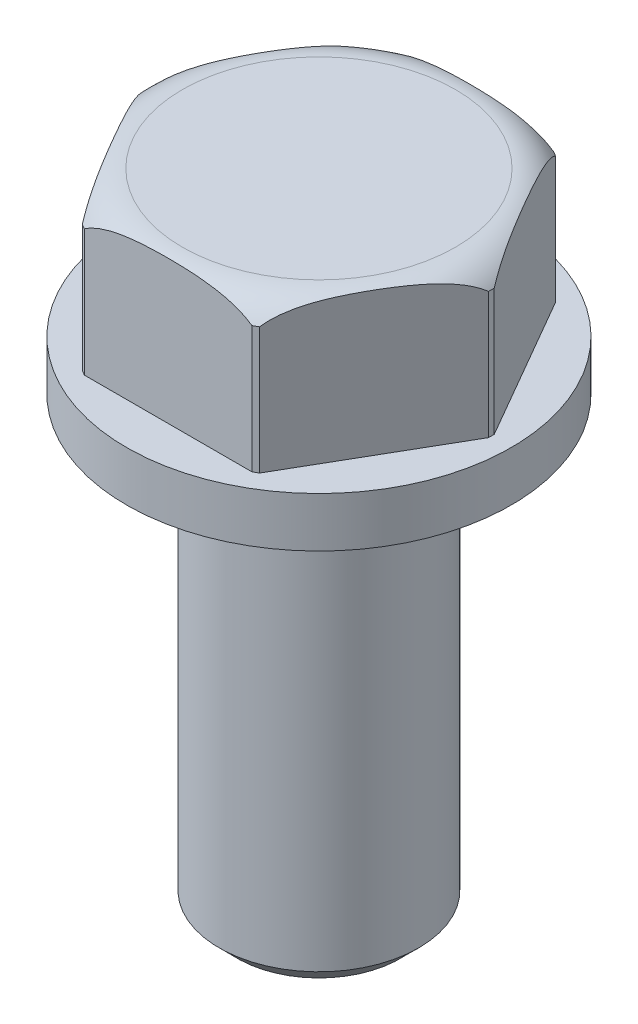
from build123d import *

# Parameters (mm, degrees)
SKETCH2_W          = 10.668
SKETCH2_H          = 4.111930553
CUT_EXTRUDE1_DEPTH = 9.271
CIRPATTERN1_COUNT  = 6
CHAMFER1_SIZE      = 1.16332


with BuildPart() as part:
    # Sketch1 → Revolve1 (revolve)
    with BuildSketch(Plane.XY):
        Polygon((0, 0), (6.35, 0), (6.35, 28.5496), (12.2555, 28.5496), (12.2555, 31.7246), (10.9855, 31.7246), (10.9855, 40.9956), (0, 40.9956), align=None)
    revolve(axis=Axis((0, 40.9956, 0), (0, -1, 0)))

    # Sketch2 → Cut-Extrude1 (cut)
    with BuildSketch(Plane(origin=(0, 40.9956, 0), x_dir=(1, 0, 0), z_dir=(0, 1, 0))):
        with Locations((0, 11.659592417)):
            Rectangle(SKETCH2_W, SKETCH2_H)
    cut_extrude1 = extrude(amount=-CUT_EXTRUDE1_DEPTH, mode=Mode.SUBTRACT)

    # CirPattern1: Cut-Extrude1 ×6 about axis
    cirpattern1_axis = Axis((0, 0, 0), (0, 1, 0))
    for i in range(1, CIRPATTERN1_COUNT):
        add(cut_extrude1.rotate(cirpattern1_axis, i * 360 / CIRPATTERN1_COUNT), mode=Mode.SUBTRACT)

    # Sketch4 → Cut-Revolve1 (revolve, cut)
    with BuildSketch(Plane.XY):
        with BuildLine():
            Line((11.176, 39.4716), (11.176, 40.9956))
            Line((11.176, 40.9956), (8.6995, 40.9956))
            ThreePointArc((8.6995, 40.9956), (10.153428149, 40.584076992), (11.176, 39.4716))
        make_face()
    revolve(axis=Axis((0, -5.042553629, 0), (0, 1, 0)), mode=Mode.SUBTRACT)

    # Chamfer1
    chamfer1_edges = [part.edges().sort_by_distance(p)[0] for p in [
        (-6.35, 0, 0),
    ]]
    chamfer(chamfer1_edges, length=CHAMFER1_SIZE)


solid = part.part
